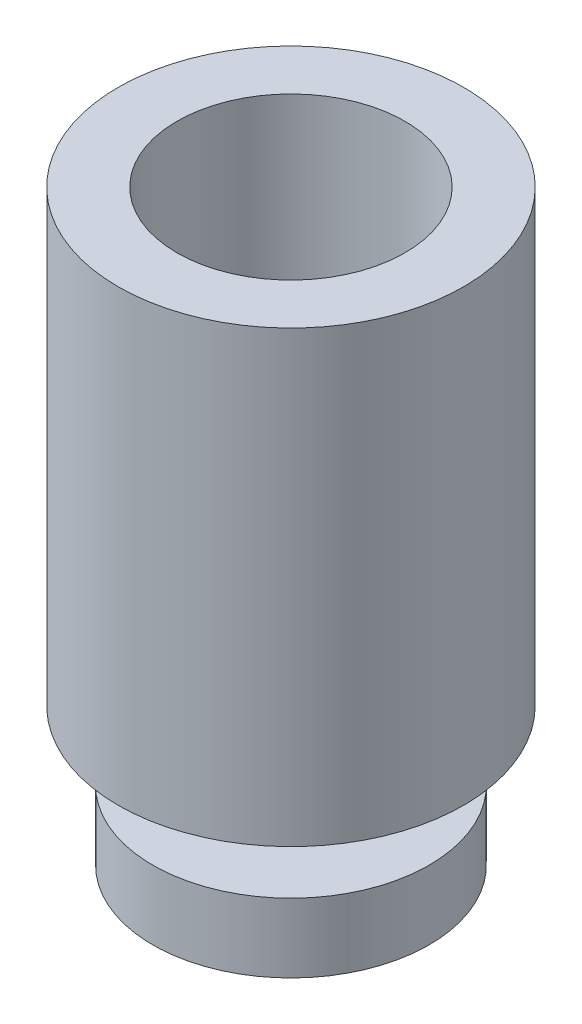
from build123d import *

# Parameters (mm, degrees)
SKETCH1_R           = 2.5
BOSS_EXTRUDE1_DEPTH = 6.5
SKETCH1_3_R         = 2
BOSS_EXTRUDE2_DEPTH = 1
SKETCH5_R           = 1
BOSS_EXTRUDE3_DEPTH = 1
SKETCH6_R           = 2
BOSS_EXTRUDE4_DEPTH = 1
SKETCH12_R          = 1.65
CUT_EXTRUDE1_DEPTH  = 5


with BuildPart() as part:
    # Sketch1 → Boss-Extrude1 (new body)
    with BuildSketch(Plane(origin=(0, 0, 0), x_dir=(1, 0, 0), z_dir=(0, 1, 0))):
        with Locations((-0.522013312, 0.511138034)):
            Circle(SKETCH1_R)
    extrude(amount=BOSS_EXTRUDE1_DEPTH)

    # Sketch1_3 → Boss-Extrude2 (add)
    with BuildSketch(Plane(origin=(0, 0, 0), x_dir=(1, 0, 0), z_dir=(0, 1, 0))):
        with Locations((-0.522013312, 0.511138034)):
            Circle(SKETCH1_3_R)
    extrude(amount=BOSS_EXTRUDE2_DEPTH)

    # Sketch5 → Boss-Extrude3 (add)
    with BuildSketch(Plane.XZ):
        with Locations((-0.522013312, -0.511138034)):
            Circle(SKETCH5_R)
    extrude(amount=BOSS_EXTRUDE3_DEPTH)

    # Sketch6 → Boss-Extrude4 (add)
    with BuildSketch(Plane.XZ.offset(1)):
        with Locations((-0.522013312, -0.511138034)):
            Circle(SKETCH6_R)
    extrude(amount=BOSS_EXTRUDE4_DEPTH)

    # Sketch12 → Cut-Extrude1 (cut)
    with BuildSketch(Plane(origin=(0, 6.5, 0), x_dir=(1, 0, 0), z_dir=(0, 1, 0))):
        with Locations((-0.522013312, 0.511138034)):
            Circle(SKETCH12_R)
    extrude(amount=-CUT_EXTRUDE1_DEPTH, mode=Mode.SUBTRACT)


solid = part.part
